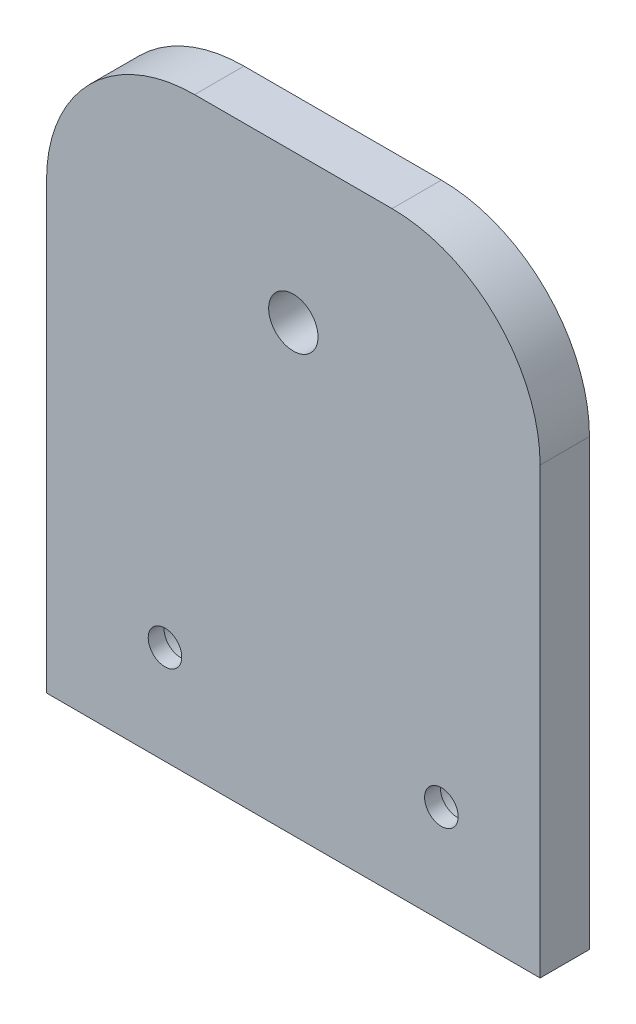
from build123d import *

# Parameters (mm, degrees)
SKIZZE1_R                                            = 2.5
AUFSATZ_LINEAR_AUSTRAGEN1_DEPTH                      = 5
STIRNSENKUNG_F_R_M3_ZYLINDERSCHRAUBE_MIT_D           = 3.4
STIRNSENKUNG_F_R_M3_ZYLINDERSCHRAUBE_MIT_CBORE_D     = 6.5
STIRNSENKUNG_F_R_M3_ZYLINDERSCHRAUBE_MIT_CBORE_DEPTH = 3.4


with BuildPart() as part:
    # Skizze1 → Aufsatz-Linear austragen1 (new body)
    with BuildSketch(Plane.XY):
        with BuildLine():
            Line((0, 0), (50, 0))
            Line((50, 0), (50, 45))
            ThreePointArc((50, 45), (45.606601718, 55.606601718), (35, 60))
            Line((35, 60), (15, 60))
            ThreePointArc((15, 60), (4.393398282, 55.606601718), (0, 45))
            Line((0, 45), (0, 0))
        make_face()
        with Locations((25, 45)):
            Circle(SKIZZE1_R, mode=Mode.SUBTRACT)
    extrude(amount=AUFSATZ_LINEAR_AUSTRAGEN1_DEPTH)

    # Stirnsenkung für M3 Zylinderschraube mit Innensechskant2 (through all)
    with Locations(Plane(origin=(0, 0, 0), x_dir=(-1, 0, 0), z_dir=(0, 0, -1))):
        with Locations((-40, 10), (-12, 10)):
            CounterBoreHole(STIRNSENKUNG_F_R_M3_ZYLINDERSCHRAUBE_MIT_D / 2, STIRNSENKUNG_F_R_M3_ZYLINDERSCHRAUBE_MIT_CBORE_D / 2, STIRNSENKUNG_F_R_M3_ZYLINDERSCHRAUBE_MIT_CBORE_DEPTH)


solid = part.part
